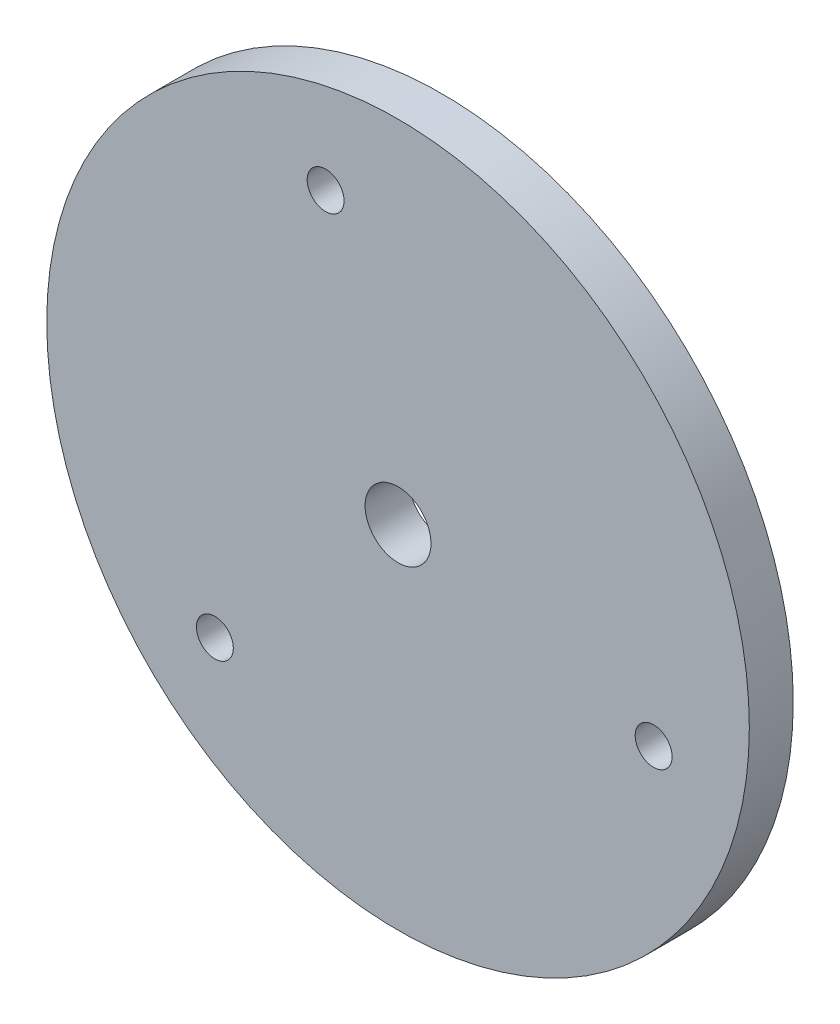
from build123d import *

# Parameters (mm, degrees)
SKETCH1_R           = 50.8
SKETCH1_R_2         = 2.667
SKETCH1_R_3         = 4.7625
BOSS_EXTRUDE1_DEPTH = 6.35


with BuildPart() as part:
    # Sketch1 → Boss-Extrude1 (new body)
    with BuildSketch(Plane.XY):
        Circle(SKETCH1_R)
        with Locations((-10.472474589, 36.632462052)):
            Circle(SKETCH1_R_2, mode=Mode.SUBTRACT)
        with Locations((36.960880035, -9.246801992)):
            Circle(SKETCH1_R_2, mode=Mode.SUBTRACT)
        with Locations((-26.488405446, -27.38566006)):
            Circle(SKETCH1_R_2, mode=Mode.SUBTRACT)
        Circle(SKETCH1_R_3, mode=Mode.SUBTRACT)
    extrude(amount=BOSS_EXTRUDE1_DEPTH)


solid = part.part
